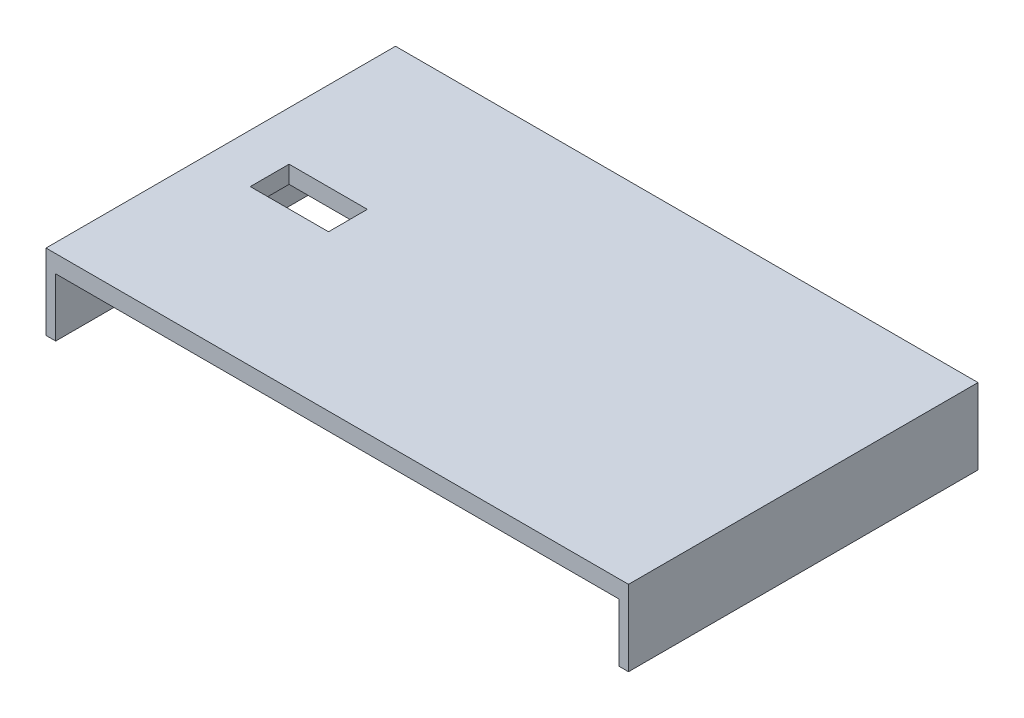
from build123d import *

# Parameters (mm, degrees)
SKETCH1_W           = 300
SKETCH1_H           = 180
BOSS_EXTRUDE1_DEPTH = 9
SKETCH2_W           = 5
SKETCH2_H           = 180
BOSS_EXTRUDE2_DEPTH = 30
SKETCH3_W           = 40.3
SKETCH3_H           = 20
CUT_EXTRUDE1_DEPTH  = 9


with BuildPart() as part:
    # Sketch1 → Boss-Extrude1 (new body)
    with BuildSketch(Plane(origin=(0, 0, 0), x_dir=(1, 0, 0), z_dir=(0, 1, 0))):
        with Locations((150, 90)):
            Rectangle(SKETCH1_W, SKETCH1_H)
    extrude(amount=BOSS_EXTRUDE1_DEPTH)

    # Sketch2 → Boss-Extrude2 (add)
    with BuildSketch(Plane.XZ):
        with Locations((2.5, -90)):
            Rectangle(SKETCH2_W, SKETCH2_H)
        with Locations((297.5, -90)):
            Rectangle(SKETCH2_W, SKETCH2_H)
    extrude(amount=BOSS_EXTRUDE2_DEPTH)

    # Sketch3 → Cut-Extrude1 (cut)
    with BuildSketch(Plane(origin=(0, 9, 0), x_dir=(1, 0, 0), z_dir=(0, 1, 0))):
        with Locations((45.35, 90)):
            Rectangle(SKETCH3_W, SKETCH3_H)
    extrude(amount=-CUT_EXTRUDE1_DEPTH, mode=Mode.SUBTRACT)


solid = part.part
